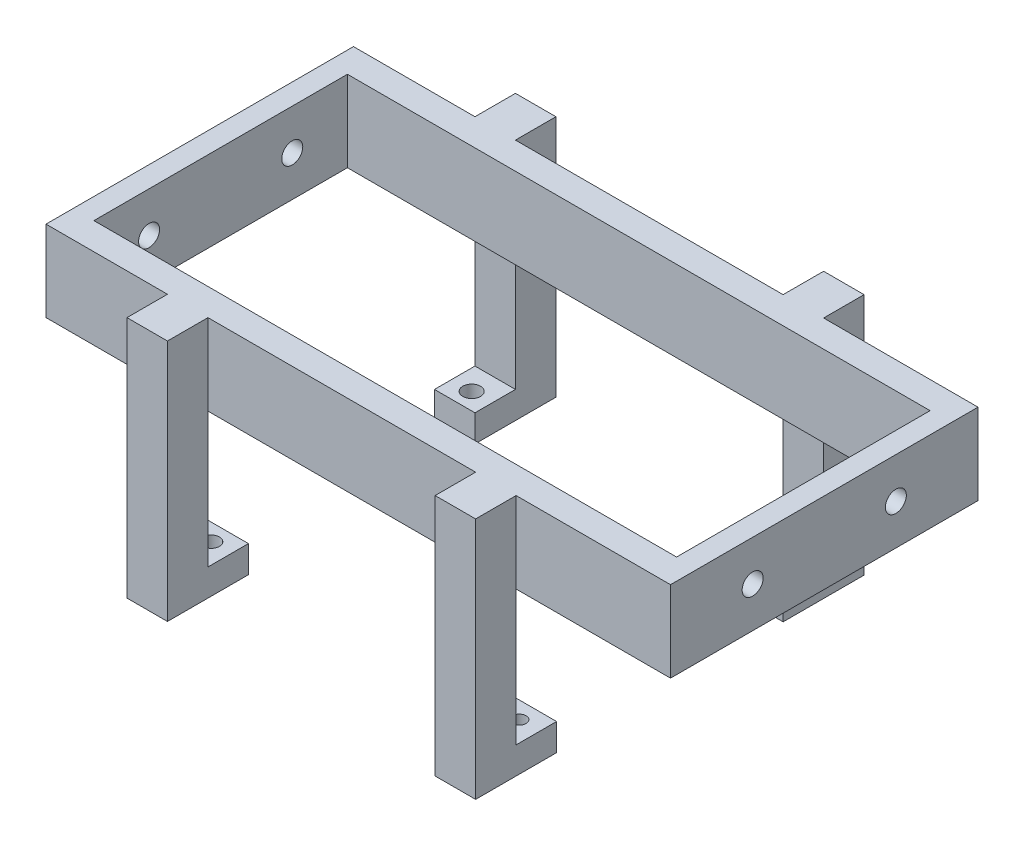
from build123d import *

# Parameters (mm, degrees)
SKETCH1_W                = 117.5385
SKETCH1_H                = 57.8739
SKETCH1_W_2              = 109.6645
SKETCH1_H_2              = 47.7139
BOSS_EXTRUDE1_DEPTH      = 15.24
SKETCH2_R                = 1.97485
CUT_EXTRUDE1_DEPTH       = 129.032
SKETCH3_W                = 7.62
SKETCH3_H                = 7.62
BOSS_EXTRUDE2_DEPTH      = 30.48
BOSS_EXTRUDE2_DEPTH_BACK = 15.24
SKETCH4_W                = 7.62
SKETCH4_H                = 7.62
SKETCH4_R                = 1.545344409
SKETCH4_R_2              = 1.269040072
SKETCH4_R_3              = 1.671154259
SKETCH4_R_4              = 1.733603543
BOSS_EXTRUDE3_DEPTH      = 5.08


with BuildPart() as part:
    # Sketch1 → Boss-Extrude1 (new body)
    with BuildSketch(Plane(origin=(0, 0, 0), x_dir=(1, 0, 0), z_dir=(0, 1, 0))):
        Rectangle(SKETCH1_W, SKETCH1_H)
        Rectangle(SKETCH1_W_2, SKETCH1_H_2, mode=Mode.SUBTRACT)
    extrude(amount=BOSS_EXTRUDE1_DEPTH)

    # Sketch2 → Cut-Extrude1 (cut)
    with BuildSketch(Plane(origin=(58.76925, 0, 0), x_dir=(0, 0, -1), z_dir=(1, 0, 0))):
        with Locations((-13.4747, 7.62)):
            Circle(SKETCH2_R)
        with Locations((13.4747, 7.62)):
            Circle(SKETCH2_R)
    extrude(amount=-CUT_EXTRUDE1_DEPTH, mode=Mode.SUBTRACT)

    # Sketch3 → Boss-Extrude2 (add, two sides)
    with BuildSketch(Plane.XZ) as boss_extrude2_sk:
        with Locations((-32.09925, 32.74695)):
            Rectangle(SKETCH3_W, SKETCH3_H)
        with Locations((25.90074068, 32.74695)):
            Rectangle(SKETCH3_W, SKETCH3_H)
        with Locations((-32.09925, -32.74695)):
            Rectangle(SKETCH3_W, SKETCH3_H)
        with Locations((25.90074068, -32.74695)):
            Rectangle(SKETCH3_W, SKETCH3_H)
    extrude(amount=BOSS_EXTRUDE2_DEPTH)
    extrude(boss_extrude2_sk.sketch, amount=-BOSS_EXTRUDE2_DEPTH_BACK)

    # Sketch4 → Boss-Extrude3 (add)
    with BuildSketch(Plane.XZ.offset(30.48)):
        with Locations((-32.09925, 25.12695)):
            Rectangle(SKETCH4_W, SKETCH4_H)
        with Locations((-32.09925, 24.511)):
            Circle(SKETCH4_R, mode=Mode.SUBTRACT)
        with Locations((25.90074068, 25.12695)):
            Rectangle(SKETCH4_W, SKETCH4_H)
        with Locations((25.90074068, 24.511)):
            Circle(SKETCH4_R_2, mode=Mode.SUBTRACT)
        with Locations((-32.09925, -25.12695)):
            Rectangle(SKETCH4_W, SKETCH4_H)
        with Locations((-32.09925, -24.511)):
            Circle(SKETCH4_R_3, mode=Mode.SUBTRACT)
        with Locations((25.90074068, -25.12695)):
            Rectangle(SKETCH4_W, SKETCH4_H)
        with Locations((25.90074068, -24.511)):
            Circle(SKETCH4_R_4, mode=Mode.SUBTRACT)
    extrude(amount=-BOSS_EXTRUDE3_DEPTH)


solid = part.part
